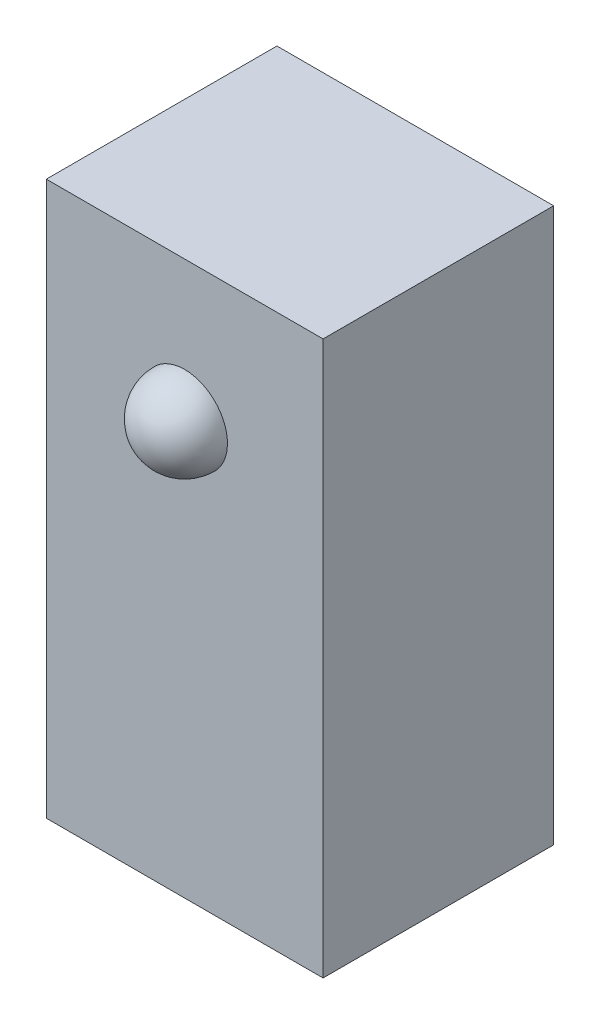
from build123d import *

# Parameters (mm, degrees)
SKETCH1_W           = 9.525
SKETCH1_H           = 7.9375
BOSS_EXTRUDE1_DEPTH = 19.05


with BuildPart() as part:
    # Sketch1 → Boss-Extrude1 (new body)
    with BuildSketch(Plane(origin=(0, 0, 0), x_dir=(1, 0, 0), z_dir=(0, 1, 0))):
        Rectangle(SKETCH1_W, SKETCH1_H)
    extrude(amount=BOSS_EXTRUDE1_DEPTH)

    # Sketch3 → Revolve1 (revolve)
    with BuildSketch(Plane(origin=(0, 0, 0), x_dir=(0, 0, -1), z_dir=(1, 0, 0))):
        with BuildLine():
            Line((-3.96875, 14.2875), (-3.96875, 15.758974771))
            ThreePointArc((-3.96875, 15.758974771), (-5.009239789, 15.327989789), (-5.440224771, 14.2875))
            Line((-5.440224771, 14.2875), (-3.96875, 14.2875))
        make_face()
    revolve(axis=Axis((0, 14.2875, 3.96875), (0, 0, 1)))


solid = part.part
